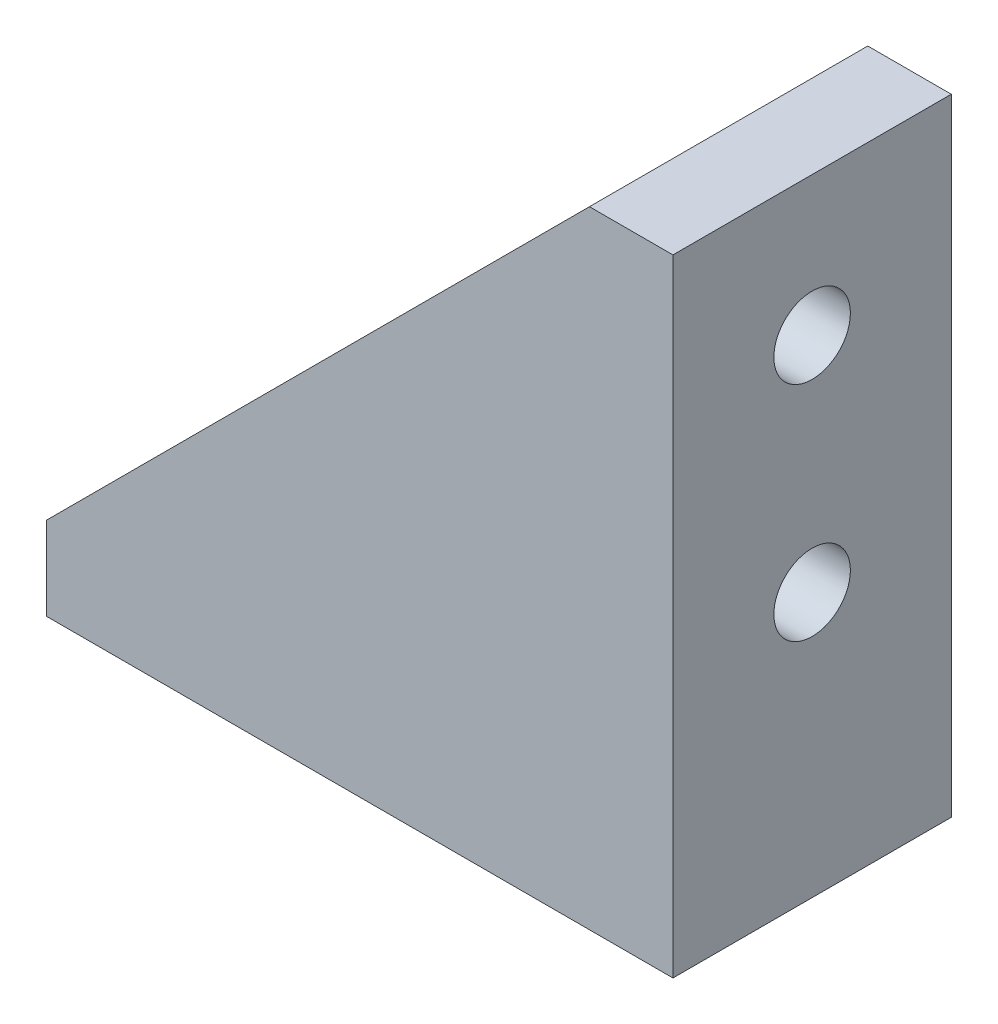
from build123d import *

# Parameters (mm, degrees)
SALIENTE_EXTRUIR1_DEPTH = 20
CROQUIS2_W              = 12
CROQUIS2_H              = 39
CORTAR_EXTRUIR1_DEPTH   = 39
CORTAR_EXTRUIR2_REACH   = 47
CROQUIS3_R              = 2.75
CORTAR_EXTRUIR3_REACH   = 47
CROQUIS4_R              = 2.75


with BuildPart() as part:
    # Croquis1 → Saliente-Extruir1 (new body)
    with BuildSketch(Plane.XY):
        Polygon((0, 0), (45, 0), (45, 45), (39, 45), (0, 6), align=None)
    extrude(amount=SALIENTE_EXTRUIR1_DEPTH)

    # Croquis2 → Cortar-Extruir1 (cut)
    with BuildSketch(Plane.ZY):
        with Locations((10, 25.5)):
            Rectangle(CROQUIS2_W, CROQUIS2_H)
    extrude(amount=-CORTAR_EXTRUIR1_DEPTH, mode=Mode.SUBTRACT)

    # Croquis3 → Cortar-Extruir2 (cut, up to next)
    with BuildSketch(Plane(origin=(45, 0, 0), x_dir=(0, 0, -1), z_dir=(1, 0, 0)), mode=Mode.PRIVATE) as cortar_extruir2_sk1:
        with Locations((-10, 35)):
            Circle(CROQUIS3_R)
    cortar_extruir2_tool1 = extrude(cortar_extruir2_sk1.sketch, amount=-CORTAR_EXTRUIR2_REACH, mode=Mode.PRIVATE) & part.part
    add(cortar_extruir2_tool1.solids().sort_by_distance((45, 35, 10))[0], mode=Mode.SUBTRACT)
    # Croquis3 → Cortar-Extruir2 (cut, up to next)
    with BuildSketch(Plane(origin=(45, 0, 0), x_dir=(0, 0, -1), z_dir=(1, 0, 0)), mode=Mode.PRIVATE) as cortar_extruir2_sk2:
        with Locations((-10, 19)):
            Circle(CROQUIS3_R)
    cortar_extruir2_tool2 = extrude(cortar_extruir2_sk2.sketch, amount=-CORTAR_EXTRUIR2_REACH, mode=Mode.PRIVATE) & part.part
    add(cortar_extruir2_tool2.solids().sort_by_distance((45, 19, 10))[0], mode=Mode.SUBTRACT)

    # Croquis4 → Cortar-Extruir3 (cut, up to next)
    with BuildSketch(Plane.XZ, mode=Mode.PRIVATE) as cortar_extruir3_sk1:
        with Locations((10, 10)):
            Circle(CROQUIS4_R)
    cortar_extruir3_tool1 = extrude(cortar_extruir3_sk1.sketch, amount=-CORTAR_EXTRUIR3_REACH, mode=Mode.PRIVATE) & part.part
    add(cortar_extruir3_tool1.solids().sort_by_distance((10, 0, 10))[0], mode=Mode.SUBTRACT)
    # Croquis4 → Cortar-Extruir3 (cut, up to next)
    with BuildSketch(Plane.XZ, mode=Mode.PRIVATE) as cortar_extruir3_sk2:
        with Locations((26, 10)):
            Circle(CROQUIS4_R)
    cortar_extruir3_tool2 = extrude(cortar_extruir3_sk2.sketch, amount=-CORTAR_EXTRUIR3_REACH, mode=Mode.PRIVATE) & part.part
    add(cortar_extruir3_tool2.solids().sort_by_distance((26, 0, 10))[0], mode=Mode.SUBTRACT)


solid = part.part
